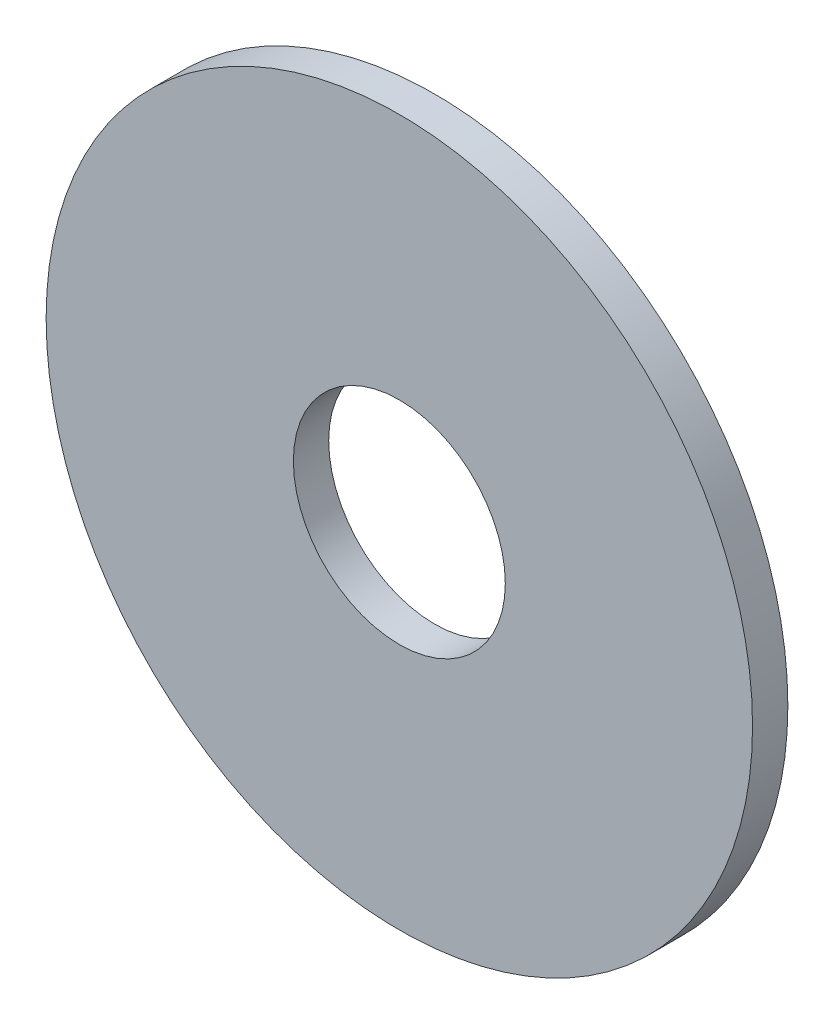
from build123d import *

# Parameters (mm, degrees)
SKETCH4_R           = 100
BOSS_EXTRUDE1_DEPTH = 10
SKETCH5_R           = 30
CUT_EXTRUDE1_DEPTH  = 10


with BuildPart() as part:
    # Sketch4 → Boss-Extrude1 (new body)
    with BuildSketch(Plane.XY):
        Circle(SKETCH4_R)
    extrude(amount=BOSS_EXTRUDE1_DEPTH)

    # Sketch5 → Cut-Extrude1 (cut)
    with BuildSketch(Plane.XY.offset(10)):
        Circle(SKETCH5_R)
    extrude(amount=-CUT_EXTRUDE1_DEPTH, mode=Mode.SUBTRACT)


solid = part.part
